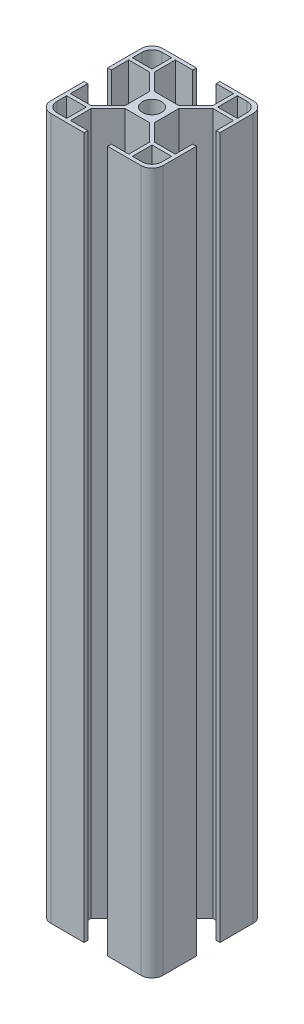
from build123d import *

# Parameters (mm, degrees)
SKETCH_1_W      = 6.2
SKETCH_1_H      = 1.3
SKETCH_1_W_2    = 1.3
SKETCH_1_H_2    = 6.2
SKETCH_1_W_3    = 10.5
SKETCH_1_H_3    = 10.5
SKETCH_1_R      = 3.4
EXTRUDE_2_DEPTH = 250


with BuildPart() as part:
    # 草图1 → 凸台-拉伸2 (new body)
    with BuildSketch(Plane(origin=(0, 0, 0), x_dir=(1, 0, 0), z_dir=(0, 1, 0))):
        with Locations((-7.3, -19.35)):
            Rectangle(SKETCH_1_W, SKETCH_1_H)
        with BuildLine():
            Line((-18.7, -10.4), (-20, -10.4))
            Line((-20, -10.4), (-20, -16.079155302))
            ThreePointArc((-20, -16.079155302), (-18.851611176, -18.851611176), (-16.079155302, -20))
            Line((-16.079155302, -20), (-10.4, -20))
            Line((-10.4, -20), (-10.4, -18.7))
            Line((-10.4, -18.7), (-10.4, -11.319238816))
            Line((-10.4, -11.319238816), (-10.4, -10.4))
            Line((-10.4, -10.4), (-11.319238816, -10.4))
            Line((-11.319238816, -10.4), (-18.7, -10.4))
        make_face()
        Polygon((-18.7, -15.2), (-18.7, -11.7), (-15.2, -11.7), (-11.7, -11.7), (-11.7, -15.2), (-11.7, -18.7), (-15.2, -18.7), (-18.7, -18.7), align=None, mode=Mode.SUBTRACT)
        with Locations((-19.35, -7.3)):
            Rectangle(SKETCH_1_W_2, SKETCH_1_H_2)
        with BuildLine():
            ThreePointArc((-15.2, -18.7), (-17.674873734, -17.674873734), (-18.7, -15.2))
            Line((-18.7, -15.2), (-18.7, -18.7))
            Line((-18.7, -18.7), (-15.2, -18.7))
        make_face()
        Polygon((-5.25, -5.25), (-5.25, -4.330761184), (-11.319238816, -10.4), (-10.4, -10.4), (-10.4, -11.319238816), (-4.330761184, -5.25), align=None)
        Rectangle(SKETCH_1_W_3, SKETCH_1_H_3)
        with Locations(Location((0, 0, 0), (0, 0, 270))):
            Circle(SKETCH_1_R, mode=Mode.SUBTRACT)
        Polygon((11.319238816, -10.4), (5.25, -4.330761184), (5.25, -5.25), (4.330761184, -5.25), (10.4, -11.319238816), (10.4, -10.4), align=None)
        Polygon((10.4, 11.319238816), (4.330761184, 5.25), (5.25, 5.25), (5.25, 4.330761184), (11.319238816, 10.4), (10.4, 10.4), align=None)
        Polygon((-4.330761184, 5.25), (-10.4, 11.319238816), (-10.4, 10.4), (-11.319238816, 10.4), (-5.25, 4.330761184), (-5.25, 5.25), align=None)
        with BuildLine():
            Line((18.7, -10.4), (11.319238816, -10.4))
            Line((11.319238816, -10.4), (10.4, -10.4))
            Line((10.4, -10.4), (10.4, -11.319238816))
            Line((10.4, -11.319238816), (10.4, -18.7))
            Line((10.4, -18.7), (10.4, -20))
            Line((10.4, -20), (16.079155302, -20))
            ThreePointArc((16.079155302, -20), (18.851611176, -18.851611176), (20, -16.079155302))
            Line((20, -16.079155302), (20, -10.4))
            Line((20, -10.4), (18.7, -10.4))
        make_face()
        Polygon((15.2, -11.7), (18.7, -11.7), (18.7, -15.2), (18.7, -18.7), (15.2, -18.7), (11.7, -18.7), (11.7, -15.2), (11.7, -11.7), align=None, mode=Mode.SUBTRACT)
        with BuildLine():
            Line((18.7, -18.7), (18.7, -15.2))
            ThreePointArc((18.7, -15.2), (17.674873734, -17.674873734), (15.2, -18.7))
            Line((15.2, -18.7), (18.7, -18.7))
        make_face()
        with BuildLine():
            Line((16.079155302, 20), (10.4, 20))
            Line((10.4, 20), (10.4, 18.7))
            Line((10.4, 18.7), (10.4, 11.319238816))
            Line((10.4, 11.319238816), (10.4, 10.4))
            Line((10.4, 10.4), (11.319238816, 10.4))
            Line((11.319238816, 10.4), (18.7, 10.4))
            Line((18.7, 10.4), (20, 10.4))
            Line((20, 10.4), (20, 16.079155302))
            ThreePointArc((20, 16.079155302), (18.851611176, 18.851611176), (16.079155302, 20))
        make_face()
        Polygon((15.2, 18.7), (18.7, 18.7), (18.7, 15.2), (18.7, 11.7), (15.2, 11.7), (11.7, 11.7), (11.7, 15.2), (11.7, 18.7), align=None, mode=Mode.SUBTRACT)
        with BuildLine():
            Line((18.7, 15.2), (18.7, 18.7))
            Line((18.7, 18.7), (15.2, 18.7))
            ThreePointArc((15.2, 18.7), (17.674873734, 17.674873734), (18.7, 15.2))
        make_face()
        with BuildLine():
            Line((-10.4, 20), (-16.079155302, 20))
            ThreePointArc((-16.079155302, 20), (-18.851611176, 18.851611176), (-20, 16.079155302))
            Line((-20, 16.079155302), (-20, 10.4))
            Line((-20, 10.4), (-18.7, 10.4))
            Line((-18.7, 10.4), (-11.319238816, 10.4))
            Line((-11.319238816, 10.4), (-10.4, 10.4))
            Line((-10.4, 10.4), (-10.4, 11.319238816))
            Line((-10.4, 11.319238816), (-10.4, 18.7))
            Line((-10.4, 18.7), (-10.4, 20))
        make_face()
        Polygon((-15.2, 11.7), (-18.7, 11.7), (-18.7, 15.2), (-18.7, 18.7), (-15.2, 18.7), (-11.7, 18.7), (-11.7, 15.2), (-11.7, 11.7), align=None, mode=Mode.SUBTRACT)
        with BuildLine():
            Line((-18.7, 18.7), (-18.7, 15.2))
            ThreePointArc((-18.7, 15.2), (-17.674873734, 17.674873734), (-15.2, 18.7))
            Line((-15.2, 18.7), (-18.7, 18.7))
        make_face()
        with Locations((-7.3, 19.35)):
            Rectangle(SKETCH_1_W, SKETCH_1_H)
        with Locations((7.3, 19.35)):
            Rectangle(SKETCH_1_W, SKETCH_1_H)
        with Locations((19.35, 7.3)):
            Rectangle(SKETCH_1_W_2, SKETCH_1_H_2)
        with Locations((-19.35, 7.3)):
            Rectangle(SKETCH_1_W_2, SKETCH_1_H_2)
        with Locations((19.35, -7.3)):
            Rectangle(SKETCH_1_W_2, SKETCH_1_H_2)
        with Locations((7.3, -19.35)):
            Rectangle(SKETCH_1_W, SKETCH_1_H)
    extrude(amount=EXTRUDE_2_DEPTH)


solid = part.part
